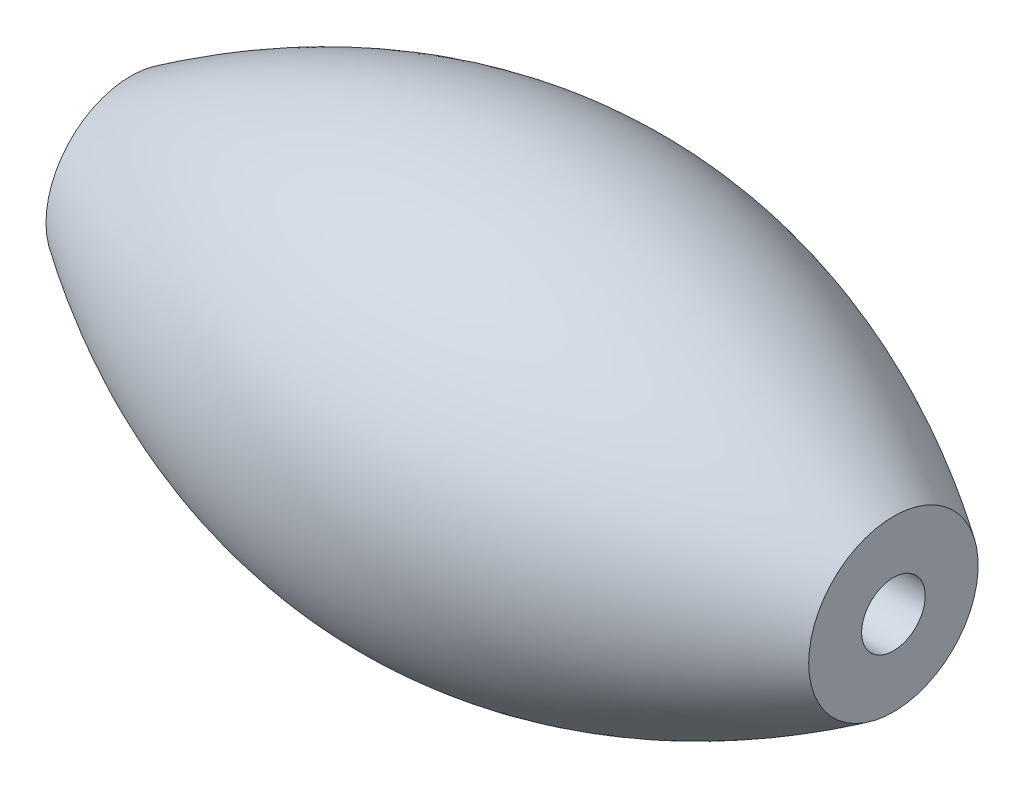
from build123d import *

# Parameters (mm, degrees)
SKETCH_2_R          = 1.5
CUT_EXTRUDE_1_DEPTH = 45


with BuildPart() as part:
    # 草图1 → 旋转1 (revolve)
    with BuildSketch(Plane.XY):
        with BuildLine():
            Line((-1.657499238, 0), (-1.657499238, 4))
            add(Edge.make_bspline(
                [(-1.657499238, 4), (-19.657499238, 16), (-37.657499238, 4)],
                knots=[0, 0, 0, 1, 1, 1], degree=2))
            Line((-37.657499238, 4), (-37.657499238, 0))
            Line((-37.657499238, 0), (-1.657499238, 0))
        make_face()
    revolve(axis=Axis((-37.657499238, 0, 0), (1, 0, 0)))

    # 草图2 → 切除-拉伸1 (cut)
    with BuildSketch(Plane(origin=(-1.657499238, 0, 0), x_dir=(0, 0, -1), z_dir=(1, 0, 0))):
        Circle(SKETCH_2_R)
    extrude(amount=-CUT_EXTRUDE_1_DEPTH, mode=Mode.SUBTRACT)


solid = part.part
